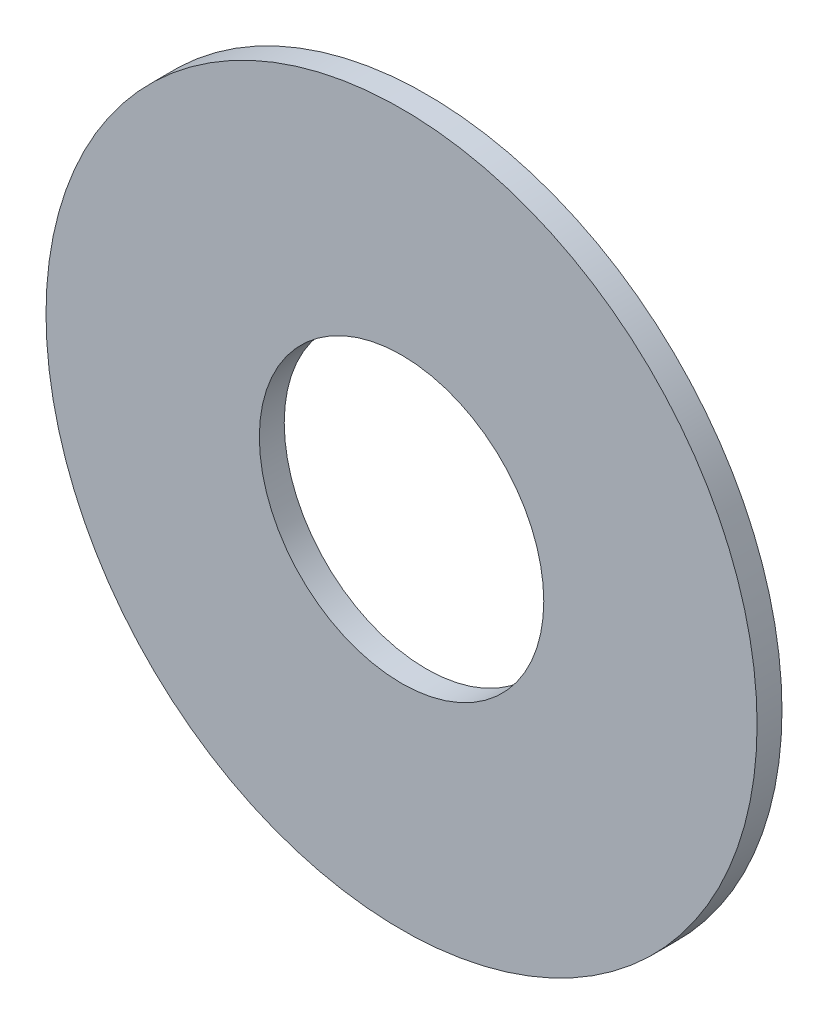
from build123d import *

# Parameters (mm, degrees)
ESQUISSE1_R             = 10
BOSS_EXTRU_1_DEPTH      = 0.7
ESQUISSE2_R             = 4
ENL_V_MAT_EXTRU_1_DEPTH = 1.5


with BuildPart() as part:
    # Esquisse1 → Boss.-Extru.1 (new body)
    with BuildSketch(Plane.XY):
        Circle(ESQUISSE1_R)
    extrude(amount=BOSS_EXTRU_1_DEPTH)

    # Esquisse2 → Enlèv. mat.-Extru.1 (cut)
    with BuildSketch(Plane.XY.offset(0.7)):
        Circle(ESQUISSE2_R)
    extrude(amount=-ENL_V_MAT_EXTRU_1_DEPTH, mode=Mode.SUBTRACT)


solid = part.part
